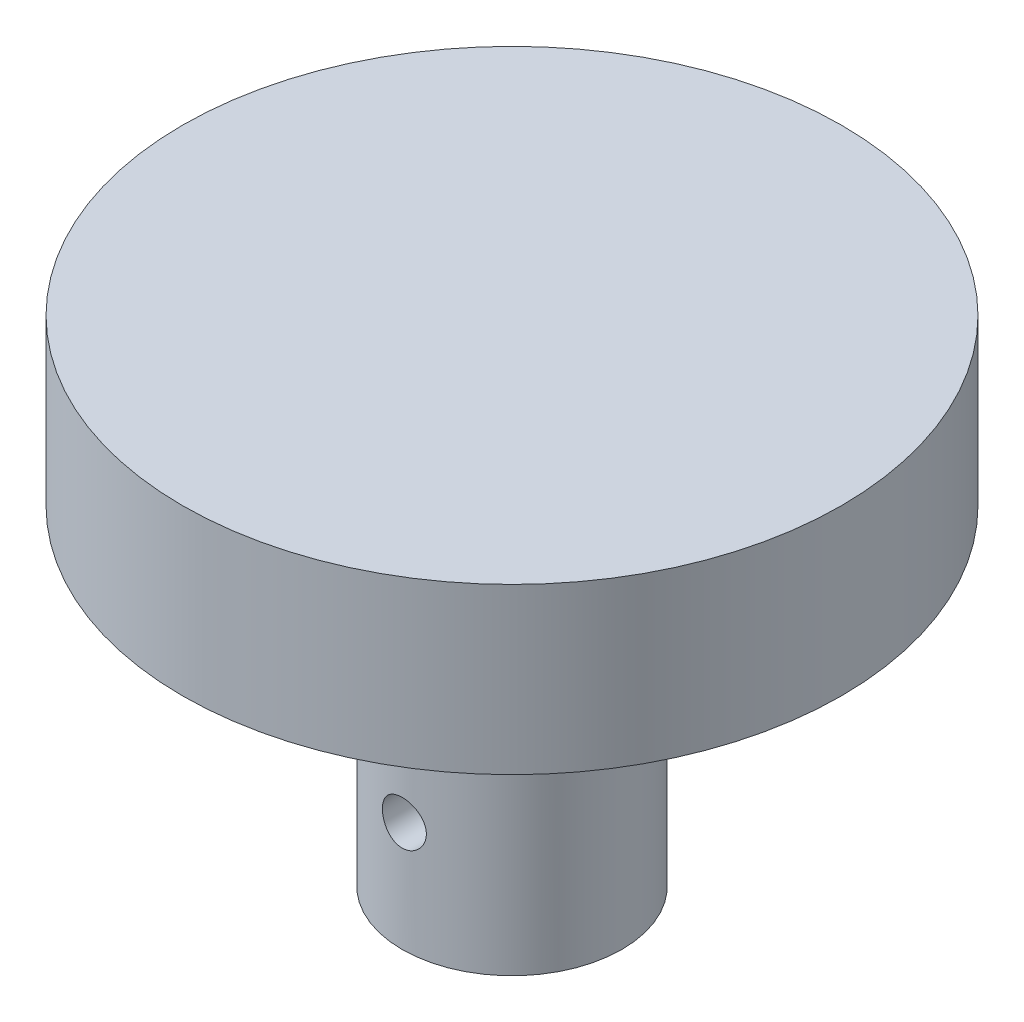
from build123d import *

# Parameters (mm, degrees)
SKETCH1_R           = 19.05
BOSS_EXTRUDE1_DEPTH = 9.525
SKETCH2_R           = 6.35
SKETCH2_R_2         = 3.5
BOSS_EXTRUDE2_DEPTH = 19.05
CUT_EXTRUDE1_REACH  = 27.4
SKETCH3_R           = 1.27


with BuildPart() as part:
    # Sketch1 → Boss-Extrude1 (new body)
    with BuildSketch(Plane(origin=(0, 0, 0), x_dir=(1, 0, 0), z_dir=(0, 1, 0))):
        Circle(SKETCH1_R)
    extrude(amount=BOSS_EXTRUDE1_DEPTH)

    # Sketch2 → Boss-Extrude2 (add)
    with BuildSketch(Plane.XZ):
        Circle(SKETCH2_R)
        Circle(SKETCH2_R_2, mode=Mode.SUBTRACT)
    extrude(amount=BOSS_EXTRUDE2_DEPTH)

    # Sketch3 → Cut-Extrude1 (cut, up to next)
    with BuildSketch(Plane.XY.offset(6.35), mode=Mode.PRIVATE) as cut_extrude1_sk1:
        with Locations((0, -12.7)):
            Circle(SKETCH3_R)
    cut_extrude1_tool1 = extrude(cut_extrude1_sk1.sketch, amount=-CUT_EXTRUDE1_REACH, mode=Mode.PRIVATE) & part.part
    add(cut_extrude1_tool1.solids().sort_by_distance((0, -12.7, 6.35))[0], mode=Mode.SUBTRACT)


solid = part.part
